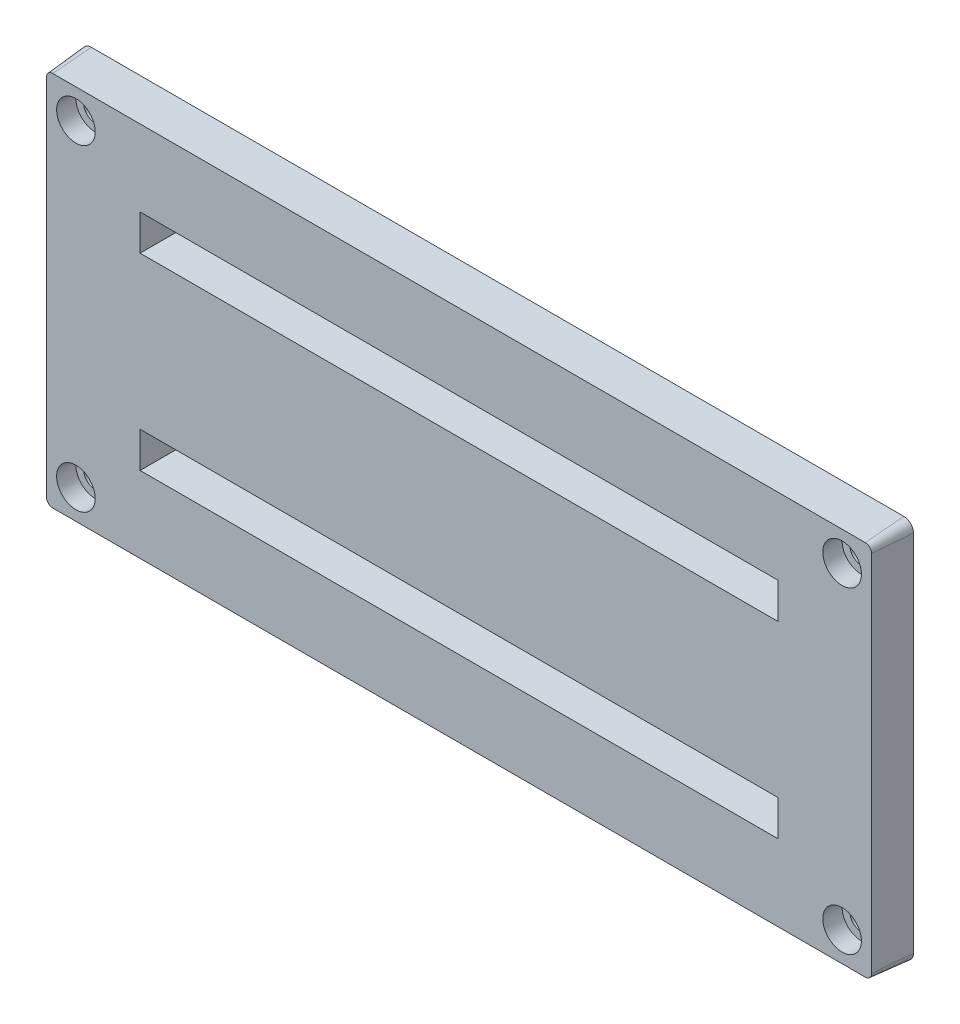
from build123d import *

# Parameters (mm, degrees)
SKETCH1_W           = 65.4
SKETCH1_H           = 3
BOSS_EXTRUDE1_DEPTH = 4
BOSS_EXTRUDE1_TAPER = 5
SKETCH2_R           = 1.2
CUT_EXTRUDE1_DEPTH  = 5.0000001
SKETCH3_R           = 2
CUT_EXTRUDE2_DEPTH  = 2


with BuildPart() as part:
    # Sketch1 → Boss-Extrude1 (new body)
    with BuildSketch(Plane.XY.offset(11.6)):
        with BuildLine():
            Line((-42.1, -10.1), (42.1, -10.1))
            ThreePointArc((42.1, -10.1), (42.807106781, -9.807106781), (43.1, -9.1))
            Line((43.1, -9.1), (43.1, 28.6))
            ThreePointArc((43.1, 28.6), (42.807106781, 29.307106781), (42.1, 29.6))
            Line((42.1, 29.6), (-42.1, 29.6))
            ThreePointArc((-42.1, 29.6), (-42.807106781, 29.307106781), (-43.1, 28.6))
            Line((-43.1, 28.6), (-43.1, -9.1))
            ThreePointArc((-43.1, -9.1), (-42.807106781, -9.807106781), (-42.1, -10.1))
        make_face()
        Rectangle(SKETCH1_W, SKETCH1_H, mode=Mode.SUBTRACT)
        with Locations((0, 19.5)):
            Rectangle(SKETCH1_W, SKETCH1_H, mode=Mode.SUBTRACT)
    extrude(amount=BOSS_EXTRUDE1_DEPTH, taper=BOSS_EXTRUDE1_TAPER)

    # Sketch2 → Cut-Extrude1 (cut, through all)
    with BuildSketch(Plane.XY.offset(15.6)):
        with Locations((-39.7, 26.2)):
            Circle(SKETCH2_R)
        with Locations((-39.7, -6.7)):
            Circle(SKETCH2_R)
        with Locations((39.7, -6.7)):
            Circle(SKETCH2_R)
        with Locations((39.7, 26.2)):
            Circle(SKETCH2_R)
    extrude(amount=-CUT_EXTRUDE1_DEPTH, mode=Mode.SUBTRACT)

    # Sketch3 → Cut-Extrude2 (cut)
    with BuildSketch(Plane.XY.offset(15.6)):
        with Locations((-39.7, 26.2)):
            Circle(SKETCH3_R)
        with Locations((-39.7, -6.7)):
            Circle(SKETCH3_R)
        with Locations((39.7, -6.7)):
            Circle(SKETCH3_R)
        with Locations((39.7, 26.2)):
            Circle(SKETCH3_R)
    extrude(amount=-CUT_EXTRUDE2_DEPTH, mode=Mode.SUBTRACT)


solid = part.part
